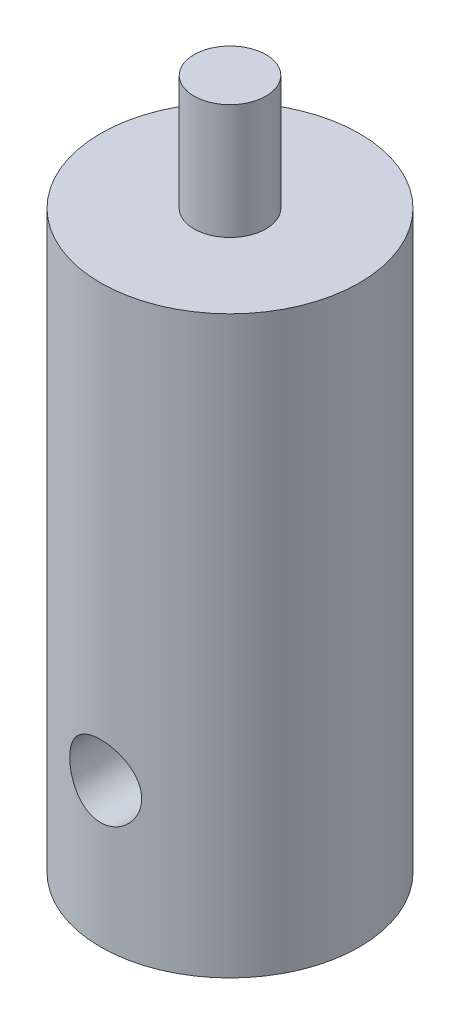
from build123d import *

# Parameters (mm, degrees)
SKETCH1_R           = 5.715
BOSS_EXTRUDE1_DEPTH = 25.4
SKETCH2_R           = 1.5875
BOSS_EXTRUDE2_DEPTH = 5.08
SKETCH4_R           = 1.5875
CUT_EXTRUDE2_DEPTH  = 6.35
SKETCH3_R           = 1.5875
CUT_EXTRUDE3_DEPTH  = 12.43


with BuildPart() as part:
    # Sketch1 → Boss-Extrude1 (new body)
    with BuildSketch(Plane(origin=(0, 0, 0), x_dir=(1, 0, 0), z_dir=(0, 1, 0))):
        Circle(SKETCH1_R)
    extrude(amount=BOSS_EXTRUDE1_DEPTH)

    # Sketch2 → Boss-Extrude2 (add)
    with BuildSketch(Plane(origin=(0, 25.4, 0), x_dir=(1, 0, 0), z_dir=(0, 1, 0))):
        Circle(SKETCH2_R)
    extrude(amount=BOSS_EXTRUDE2_DEPTH)

    # Sketch4 → Cut-Extrude2 (cut)
    with BuildSketch(Plane.XZ):
        Circle(SKETCH4_R)
    extrude(amount=-CUT_EXTRUDE2_DEPTH, mode=Mode.SUBTRACT)

    # Sketch3 → Cut-Extrude3 (cut, through all)
    with BuildSketch(Plane.XY.offset(5.715)):
        with Locations((0, 6.35)):
            Circle(SKETCH3_R)
    extrude(amount=-CUT_EXTRUDE3_DEPTH, mode=Mode.SUBTRACT)


solid = part.part
